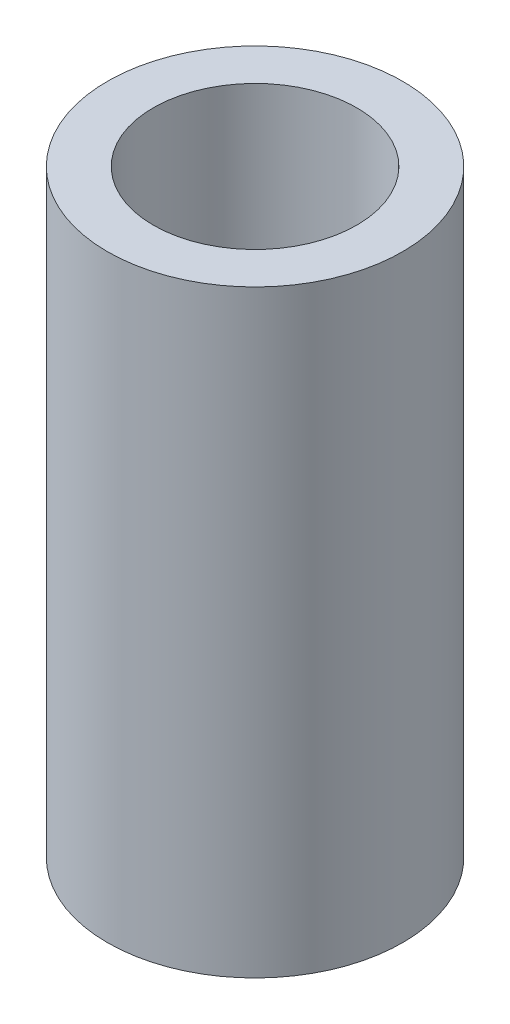
from build123d import *

# Parameters (mm, degrees)
SKETCH1_R               = 7.4
BOSS_EXTRUDE1_DEPTH     = 30
M12X1_75_TAPPED_HOLE1_D = 10.2


with BuildPart() as part:
    # Sketch1 → Boss-Extrude1 (new body)
    with BuildSketch(Plane(origin=(0, 0, 0), x_dir=(1, 0, 0), z_dir=(0, 1, 0))):
        Circle(SKETCH1_R)
    extrude(amount=BOSS_EXTRUDE1_DEPTH)

    # M12x1.75 Tapped Hole1 (through all)
    with Locations(Plane(origin=(0, 30, 0), x_dir=(1, 0, 0), z_dir=(0, 1, 0))):
        with Locations((0, 0)):
            Hole(M12X1_75_TAPPED_HOLE1_D / 2)


solid = part.part
